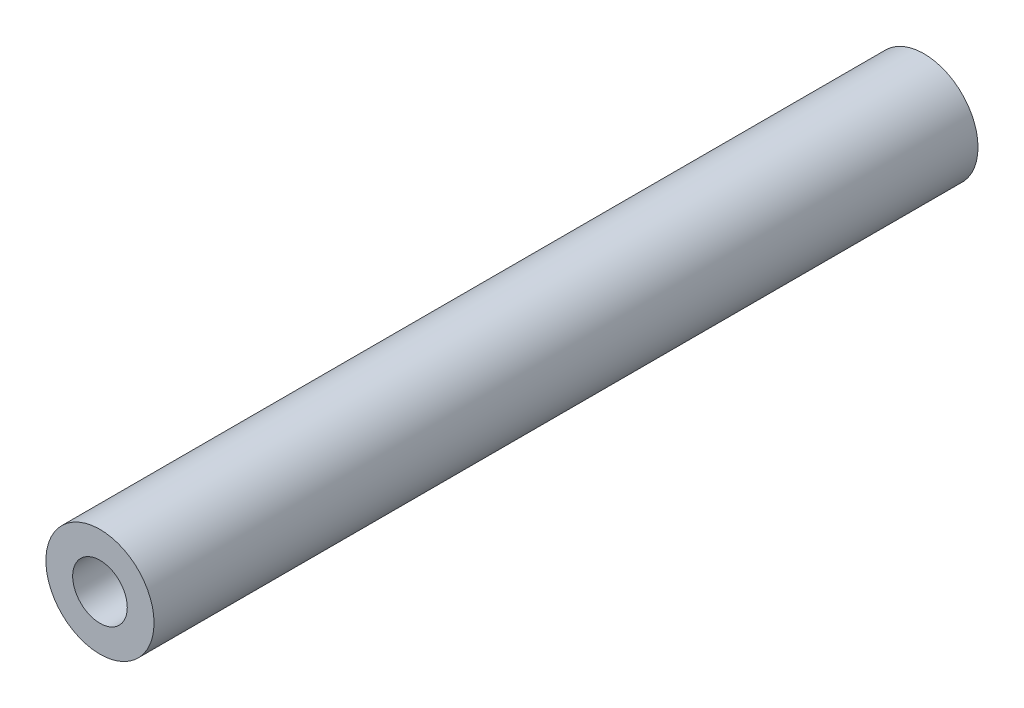
from build123d import *

# Parameters (mm, degrees)
SKETCH1_R           = 5
BOSS_EXTRUDE1_DEPTH = 76.2
SKETCH2_R           = 2.525
CUT_EXTRUDE1_DEPTH  = 6


with BuildPart() as part:
    # Sketch1 → Boss-Extrude1 (new body)
    with BuildSketch(Plane.XY):
        Circle(SKETCH1_R)
    extrude(amount=BOSS_EXTRUDE1_DEPTH)

    # Sketch2 → Cut-Extrude1 (cut)
    with BuildSketch(Plane.XY.offset(76.2)):
        Circle(SKETCH2_R)
    cut_extrude1 = extrude(amount=-CUT_EXTRUDE1_DEPTH, mode=Mode.SUBTRACT)

    # Mirror1: Cut-Extrude1 across plane
    add(cut_extrude1.mirror(Plane(origin=(0, 0, 38.1), x_dir=(1, 0, 0), z_dir=(0, 0, -1))), mode=Mode.SUBTRACT)


solid = part.part
